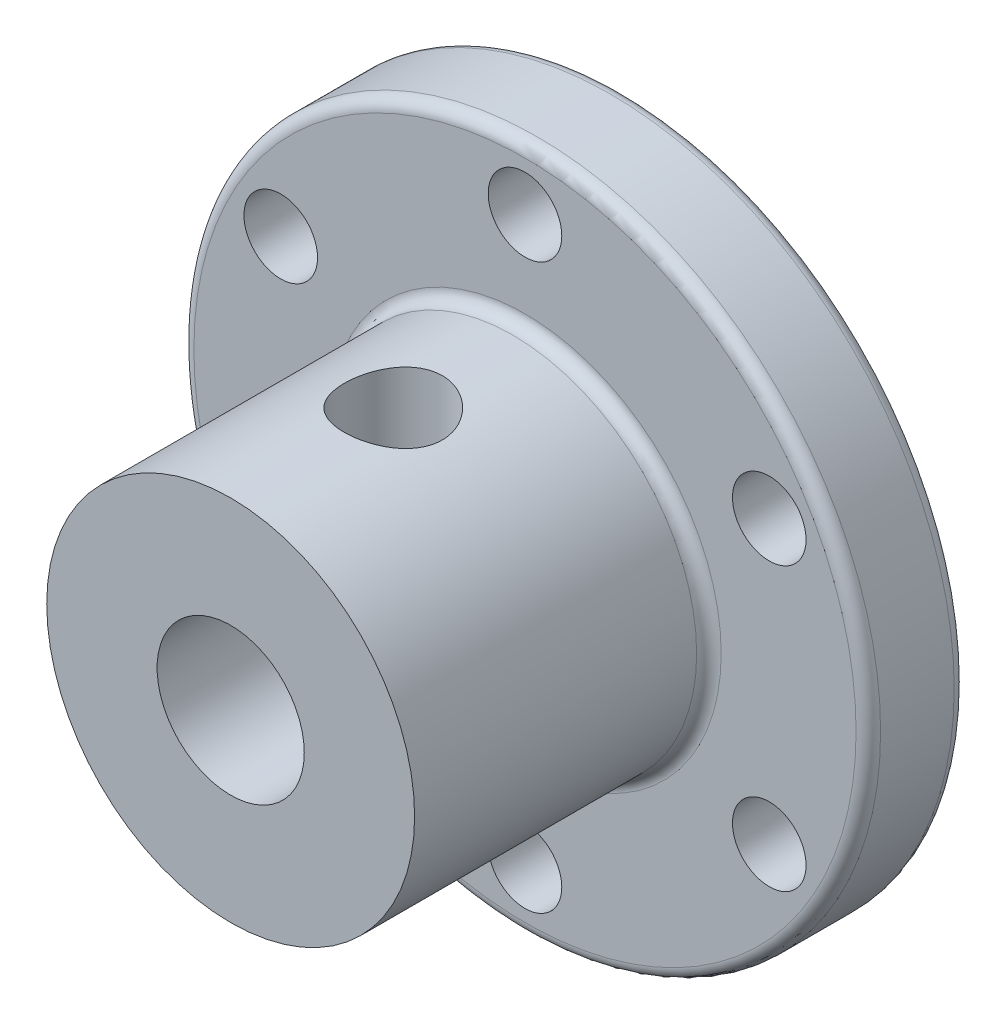
from build123d import *

# Parameters (mm, degrees)
SKETCH_1_R          = 14
SKETCH_1_R_2        = 1.5
EXTRUDE_1_DEPTH     = 4
SKETCH_2_R          = 7.5
EXTRUDE_2_DEPTH     = 12
SKETCH_3_R          = 3
CUT_EXTRUDE_1_DEPTH = 17
FILLET_1_R          = 0.5
FILLET_2_R          = 0.5
SKETCH_4_R          = 2
CUT_EXTRUDE_3_DEPTH = 15.0000001


with BuildPart() as part:
    # 草图1 → 凸台-拉伸1 (new body)
    with BuildSketch(Plane.XY):
        Circle(SKETCH_1_R)
        with Locations((0, 11.5)):
            Circle(SKETCH_1_R_2, mode=Mode.SUBTRACT)
        with Locations((9.959292144, 5.75)):
            Circle(SKETCH_1_R_2, mode=Mode.SUBTRACT)
        with Locations((9.959292144, -5.75)):
            Circle(SKETCH_1_R_2, mode=Mode.SUBTRACT)
        with Locations((0, -11.5)):
            Circle(SKETCH_1_R_2, mode=Mode.SUBTRACT)
        with Locations((-9.959292144, -5.75)):
            Circle(SKETCH_1_R_2, mode=Mode.SUBTRACT)
        with Locations((-9.959292144, 5.75)):
            Circle(SKETCH_1_R_2, mode=Mode.SUBTRACT)
    extrude(amount=EXTRUDE_1_DEPTH)

    # 草图2 → 凸台-拉伸2 (add)
    with BuildSketch(Plane.XY.offset(4)):
        Circle(SKETCH_2_R)
    extrude(amount=EXTRUDE_2_DEPTH)

    # 草图3 → 切除-拉伸1 (cut, through all)
    with BuildSketch(Plane.XY.offset(16)):
        Circle(SKETCH_3_R)
    extrude(amount=-CUT_EXTRUDE_1_DEPTH, mode=Mode.SUBTRACT)

    # 圆角1
    fillet_1_edges = [part.edges().sort_by_distance(p)[0] for p in [
        (-14, 0, 0),
        (-14, 0, 4),
    ]]
    fillet(fillet_1_edges, radius=FILLET_1_R)

    # 圆角2
    fillet_2_edges = [part.edges().sort_by_distance(p)[0] for p in [
        (-7.5, 0, 4),
    ]]
    fillet(fillet_2_edges, radius=FILLET_2_R)

    # 草图4 → 切除-拉伸3 (cut, through all)
    with BuildSketch(Plane(origin=(0, 0, 0), x_dir=(1, 0, 0), z_dir=(0, 1, 0))):
        with Locations((0, -9.370984313)):
            Circle(SKETCH_4_R)
    extrude(amount=CUT_EXTRUDE_3_DEPTH, mode=Mode.SUBTRACT)


solid = part.part
